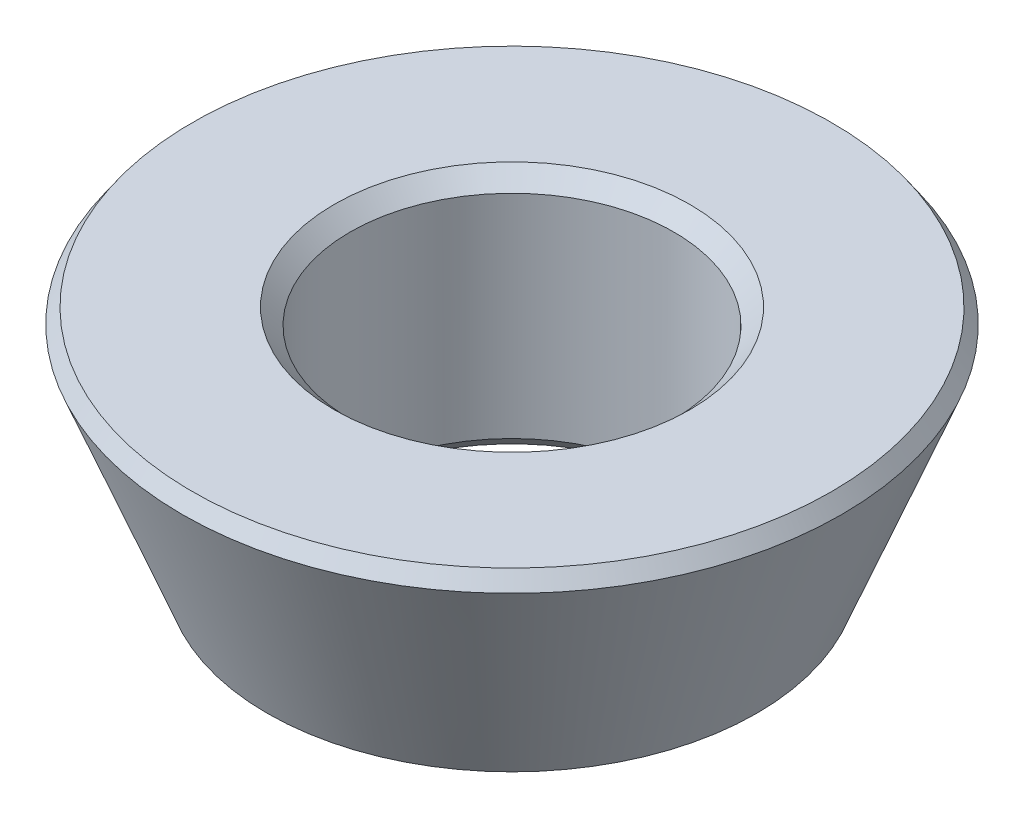
from build123d import *

# Parameters (mm, degrees)
CHAMFER3_SIZE = 0.3


with BuildPart() as part:
    # Sketch3 → Revolve1 (revolve)
    with BuildSketch(Plane.XY):
        Polygon((3.05, 4.6), (3.05, 0), (4.5, 0), (6.31983867, 4.6), align=None)
    revolve(axis=Axis((0, 4.6, 0), (0, -1, 0)))

    # Chamfer3
    chamfer3_edges = [part.edges().sort_by_distance(p)[0] for p in [
        (-6.31983867, 4.6, 0),
        (-4.5, 0, 0),
        (-3.05, 0, 0),
        (-3.05, 4.6, 0),
    ]]
    chamfer(chamfer3_edges, length=CHAMFER3_SIZE)


solid = part.part
